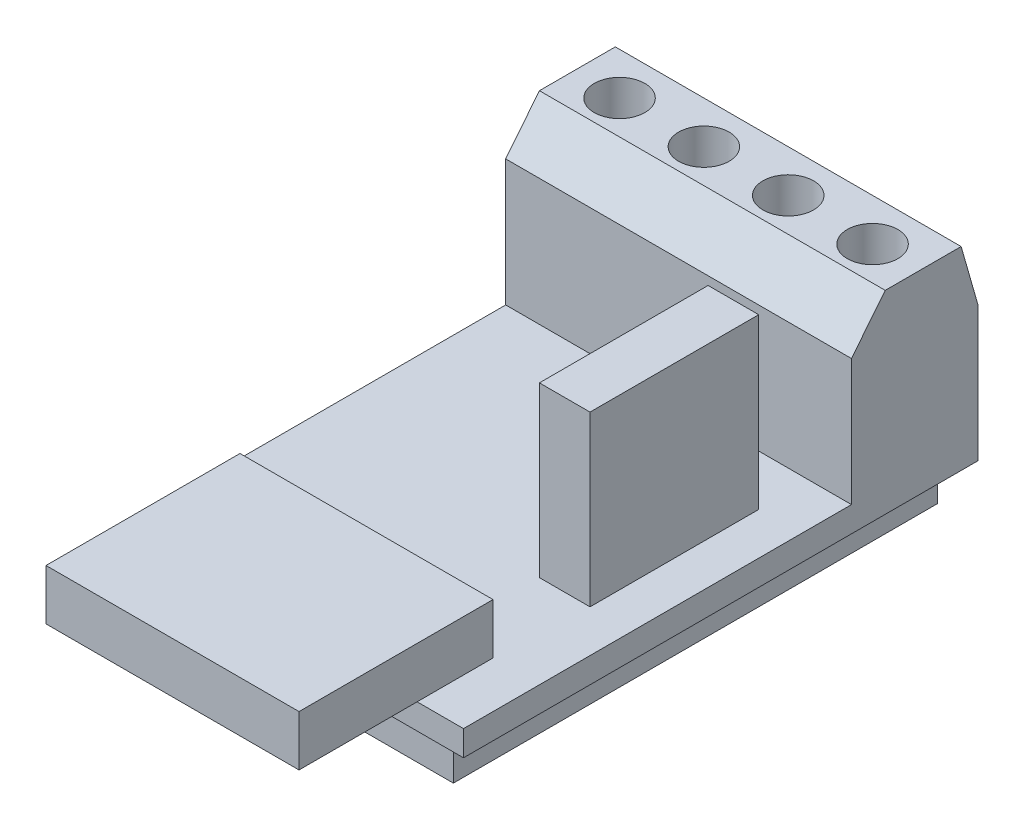
from build123d import *

# Parameters (mm, degrees)
SKETCH1_W           = 20.5
SKETCH1_H           = 30.5
BOSS_EXTRUDE1_DEPTH = 1.5
SKETCH2_W           = 15
SKETCH2_H           = 11.5
BOSS_EXTRUDE2_DEPTH = 3
SKETCH3_W           = 3
SKETCH3_H           = 10
BOSS_EXTRUDE3_DEPTH = 10
SKETCH4_W           = 20.5
SKETCH4_H           = 7.5
BOSS_EXTRUDE4_DEPTH = 10
SKETCH5_W           = 4.125
SKETCH5_H           = 5
CUT_EXTRUDE1_DEPTH  = 3
CHAMFER1_SIZE       = 2.5
CHAMFER1_SIZE2      = 2
CHAMFER2_SIZE       = 3.5
CHAMFER2_SIZE2      = 1
SKETCH6_R           = 1.5
CUT_EXTRUDE2_DEPTH  = 3
SKETCH8_W           = 17.5
SKETCH8_H           = 28.7
BOSS_EXTRUDE5_DEPTH = 2.5


with BuildPart() as part:
    # Sketch1 → Boss-Extrude1 (new body)
    with BuildSketch(Plane(origin=(0, 0, 0), x_dir=(1, 0, 0), z_dir=(0, 1, 0))):
        Rectangle(SKETCH1_W, SKETCH1_H)
    extrude(amount=BOSS_EXTRUDE1_DEPTH)

    # Sketch2 → Boss-Extrude2 (add)
    with BuildSketch(Plane(origin=(0, 1.5, 0), x_dir=(1, 0, 0), z_dir=(0, 1, 0))):
        with Locations((0, -16.5)):
            Rectangle(SKETCH2_W, SKETCH2_H)
    extrude(amount=BOSS_EXTRUDE2_DEPTH)

    # Sketch3 → Boss-Extrude3 (add)
    with BuildSketch(Plane(origin=(0, 1.5, 0), x_dir=(1, 0, 0), z_dir=(0, 1, 0))):
        with Locations((6.25, -0.25)):
            Rectangle(SKETCH3_W, SKETCH3_H)
    extrude(amount=BOSS_EXTRUDE3_DEPTH)

    # Sketch4 → Boss-Extrude4 (add)
    with BuildSketch(Plane(origin=(0, 1.5, 0), x_dir=(1, 0, 0), z_dir=(0, 1, 0))):
        with Locations((0, 11.5)):
            Rectangle(SKETCH4_W, SKETCH4_H)
    extrude(amount=BOSS_EXTRUDE4_DEPTH)

    # Sketch5 → Cut-Extrude1 (cut)
    with BuildSketch(Plane(origin=(0, 0, -15.25), x_dir=(-1, 0, 0), z_dir=(0, 0, -1))):
        with Locations((-7.6875, 5)):
            Rectangle(SKETCH5_W, SKETCH5_H)
        with Locations((-2.5625, 5)):
            Rectangle(SKETCH5_W, SKETCH5_H)
        with Locations((2.5625, 5)):
            Rectangle(SKETCH5_W, SKETCH5_H)
        with Locations((7.6875, 5)):
            Rectangle(SKETCH5_W, SKETCH5_H)
    extrude(amount=-CUT_EXTRUDE1_DEPTH, mode=Mode.SUBTRACT)

    # Chamfer1
    chamfer1_edges = [part.edges().sort_by_distance(p)[0] for p in [
        (0, 11.5, -7.75),
    ]]
    chamfer1_side = [part.faces().sort_by_distance(p)[0] for p in [
        (0, 6.5, -7.75),
    ]]
    chamfer(chamfer1_edges, length=CHAMFER1_SIZE, length2=CHAMFER1_SIZE2, reference=chamfer1_side[0])

    # Chamfer2
    chamfer2_edges = [part.edges().sort_by_distance(p)[0] for p in [
        (0, 11.5, -15.25),
    ]]
    chamfer2_side = [part.faces().sort_by_distance(p)[0] for p in [
        (0, 6.153752039, -15.25),
    ]]
    chamfer(chamfer2_edges, length=CHAMFER2_SIZE, length2=CHAMFER2_SIZE2, reference=chamfer2_side[0])

    # Sketch6 → Cut-Extrude2 (cut)
    with BuildSketch(Plane(origin=(0, 11.5, 0), x_dir=(1, 0, 0), z_dir=(0, 1, 0))):
        with Locations((-7.5, 11.75)):
            Circle(SKETCH6_R)
        with Locations((-2.5, 11.75)):
            Circle(SKETCH6_R)
        with Locations((2.5, 11.75)):
            Circle(SKETCH6_R)
        with Locations((7.5, 11.75)):
            Circle(SKETCH6_R)
    extrude(amount=-CUT_EXTRUDE2_DEPTH, mode=Mode.SUBTRACT)

    # Sketch8 → Boss-Extrude5 (add)
    with BuildSketch(Plane.XZ):
        Rectangle(SKETCH8_W, SKETCH8_H)
    extrude(amount=BOSS_EXTRUDE5_DEPTH)


solid = part.part
